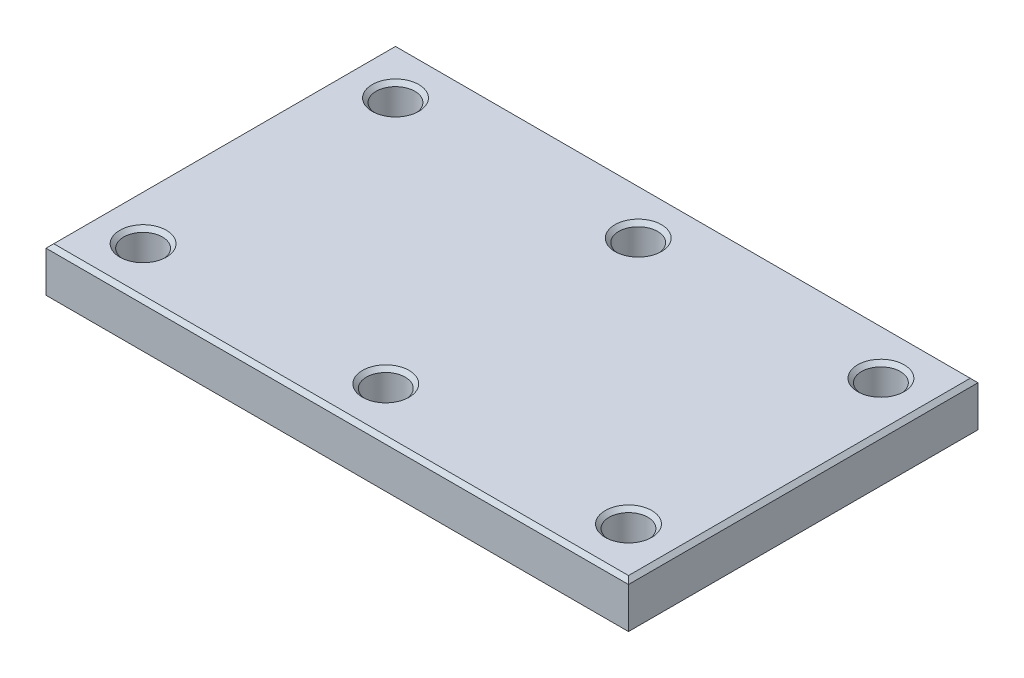
from build123d import *

# Parameters (mm, degrees)
SKETCH1_W           = 300
SKETCH1_H           = 180
BOSS_EXTRUDE1_DEPTH = 12.5
SKETCH2_R           = 10
CUT_EXTRUDE1_DEPTH  = 25
CHAMFER1_SIZE       = 2
CHAMFER2_SIZE       = 2


with BuildPart() as part:
    # Sketch1 → Boss-Extrude1 (new body, symmetric)
    with BuildSketch(Plane(origin=(0, 0, 0), x_dir=(1, 0, 0), z_dir=(0, 1, 0))):
        Rectangle(SKETCH1_W, SKETCH1_H)
    extrude(amount=BOSS_EXTRUDE1_DEPTH, both=True)

    # Sketch2 → Cut-Extrude1 (cut)
    with BuildSketch(Plane(origin=(0, 12.5, 0), x_dir=(1, 0, 0), z_dir=(0, 1, 0))):
        with Locations((-125, 65)):
            Circle(SKETCH2_R)
        with Locations((0, 65)):
            Circle(SKETCH2_R)
        with Locations((125, 65)):
            Circle(SKETCH2_R)
        with Locations((0, -65)):
            Circle(SKETCH2_R)
        with Locations((125, -65)):
            Circle(SKETCH2_R)
        with Locations((-125, -65)):
            Circle(SKETCH2_R)
    extrude(amount=-CUT_EXTRUDE1_DEPTH, mode=Mode.SUBTRACT)

    # Chamfer1
    chamfer1_edges = [part.edges().sort_by_distance(p)[0] for p in [
        (-150, 12.5, 0),
        (0, 12.5, 90),
        (-135, 12.5, -65),
        (-10, 12.5, -65),
        (115, 12.5, -65),
        (-10, 12.5, 65),
        (115, 12.5, 65),
        (-135, 12.5, 65),
        (150, 12.5, 0),
        (0, 12.5, -90),
    ]]
    chamfer(chamfer1_edges, length=CHAMFER1_SIZE)

    # Chamfer2
    chamfer2_edges = [part.edges().sort_by_distance(p)[0] for p in [
        (-135, -12.5, -65),
        (-10, -12.5, -65),
        (115, -12.5, -65),
        (-10, -12.5, 65),
        (115, -12.5, 65),
        (-135, -12.5, 65),
        (0, -12.5, 90),
        (-150, -12.5, 0),
        (0, -12.5, -90),
        (150, -12.5, 0),
    ]]
    chamfer(chamfer2_edges, length=CHAMFER2_SIZE)


solid = part.part
